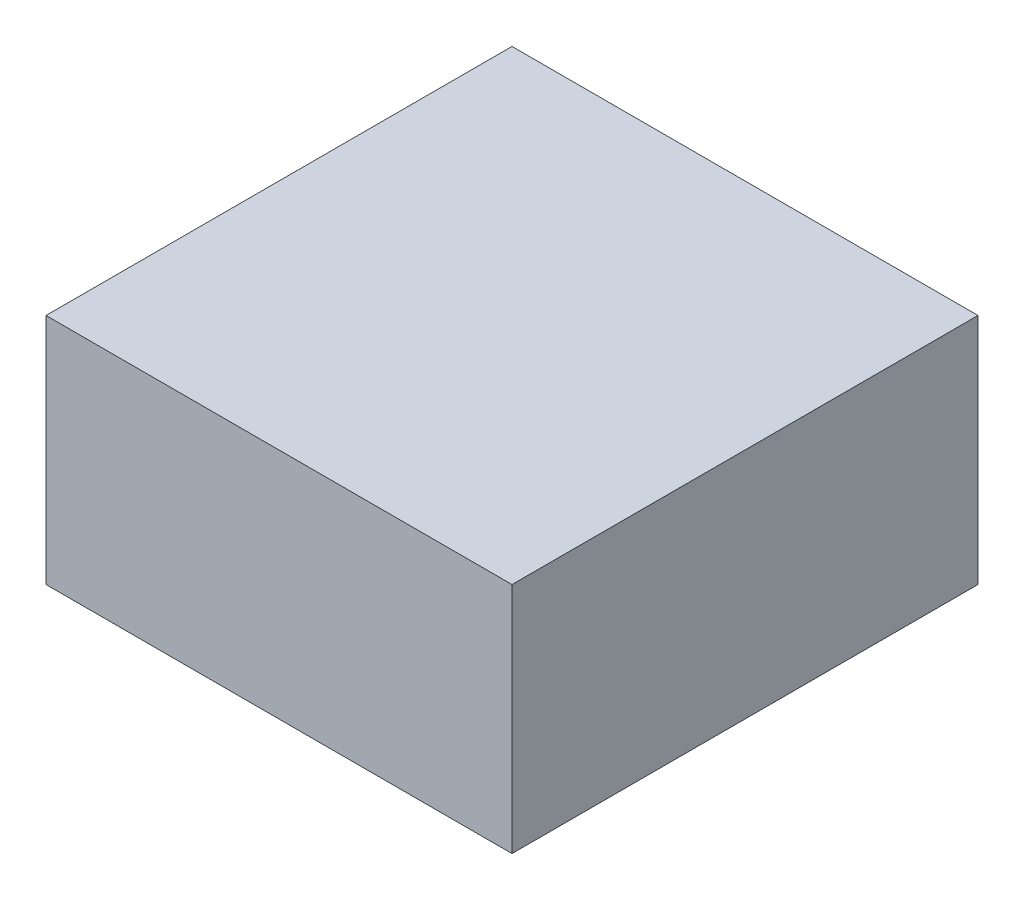
from build123d import *

# Parameters (mm, degrees)
SKETCH1_W           = 0.2
SKETCH1_H           = 0.2
BOSS_EXTRUDE1_DEPTH = 0.1


with BuildPart() as part:
    # Sketch1 → Boss-Extrude1 (new body)
    with BuildSketch(Plane(origin=(0, 0, 0), x_dir=(1, 0, 0), z_dir=(0, 1, 0))):
        Rectangle(SKETCH1_W, SKETCH1_H)
    extrude(amount=BOSS_EXTRUDE1_DEPTH)


solid = part.part
